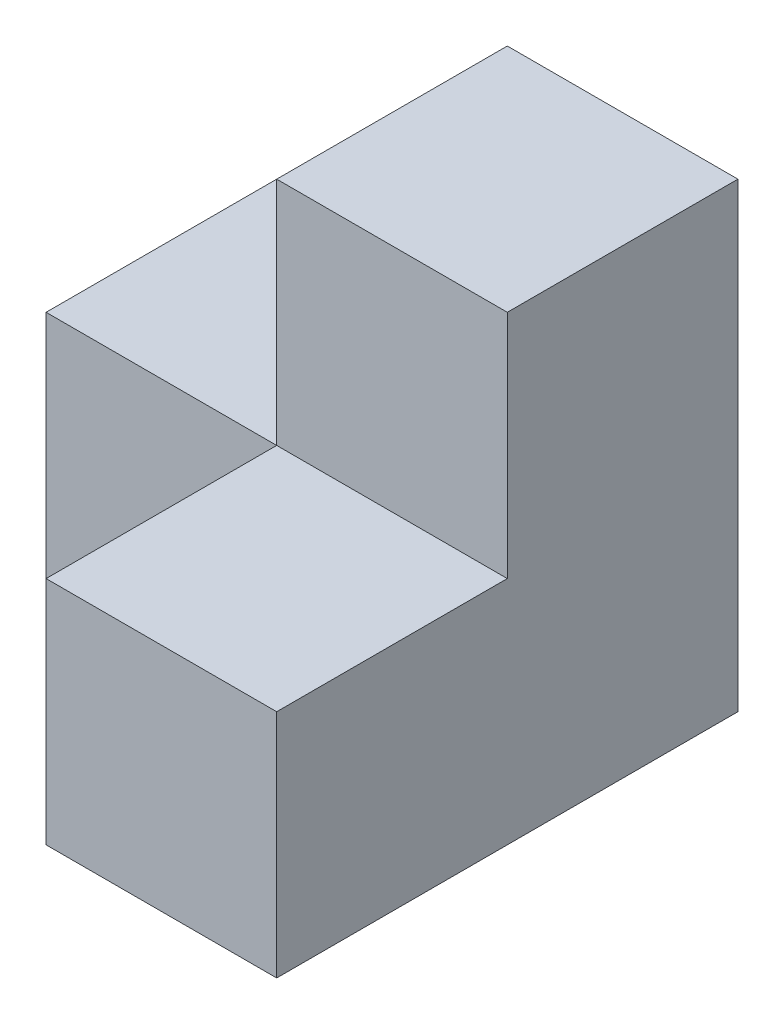
from build123d import *

# Parameters (mm, degrees)
SKETCH1_W           = 50.8
SKETCH1_H           = 50.8
BOSS_EXTRUDE1_DEPTH = 25.4
SKETCH2_W           = 25.4
SKETCH2_H           = 25.4
CUT_EXTRUDE1_DEPTH  = 26.4
SKETCH3_W           = 25.4
SKETCH3_H           = 25.4
BOSS_EXTRUDE2_DEPTH = 25.4


with BuildPart() as part:
    # Sketch1 → Boss-Extrude1 (new body)
    with BuildSketch(Plane(origin=(0, 0, 0), x_dir=(1, 0, 0), z_dir=(0, 1, 0))):
        Rectangle(SKETCH1_W, SKETCH1_H)
    extrude(amount=BOSS_EXTRUDE1_DEPTH)

    # Sketch2 → Cut-Extrude1 (cut, through all)
    with BuildSketch(Plane(origin=(0, 25.4, 0), x_dir=(1, 0, 0), z_dir=(0, 1, 0))):
        with Locations((-12.7, -12.7)):
            Rectangle(SKETCH2_W, SKETCH2_H)
    extrude(amount=-CUT_EXTRUDE1_DEPTH, mode=Mode.SUBTRACT)

    # Sketch3 → Boss-Extrude2 (add)
    with BuildSketch(Plane(origin=(0, 25.4, 0), x_dir=(1, 0, 0), z_dir=(0, 1, 0))):
        with Locations((12.7, 12.7)):
            Rectangle(SKETCH3_W, SKETCH3_H)
    extrude(amount=BOSS_EXTRUDE2_DEPTH)


solid = part.part
